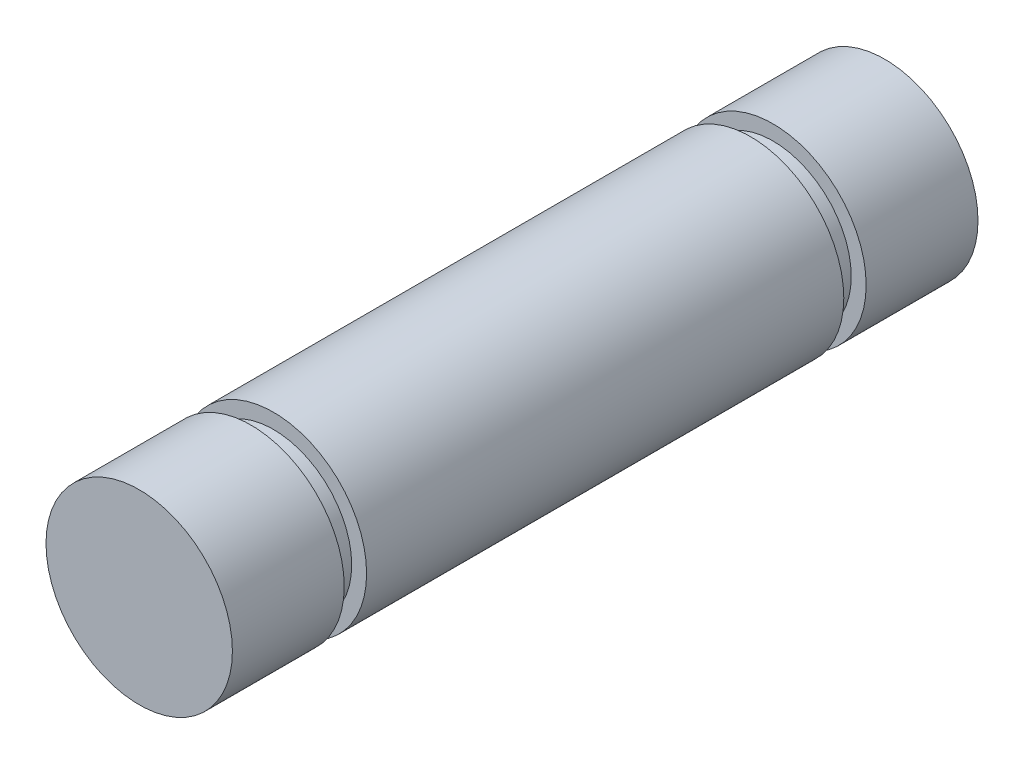
from build123d import *

# Parameters (mm, degrees)
SKETCH1_R           = 3.175
BOSS_EXTRUDE1_DEPTH = 12.7
SKETCH2_W           = 0.508
SKETCH2_H           = 0.762


with BuildPart() as part:
    # Sketch1 → Boss-Extrude1 (new body, symmetric)
    with BuildSketch(Plane.XY):
        Circle(SKETCH1_R)
    extrude(amount=BOSS_EXTRUDE1_DEPTH, both=True)

    # Sketch2 → Cut-Revolve1 (revolve, cut)
    with BuildSketch(Plane(origin=(0, 0, 0), x_dir=(1, 0, 0), z_dir=(0, 1, 0))):
        with Locations((2.921, 8.509)):
            Rectangle(SKETCH2_W, SKETCH2_H)
        with Locations((2.921, -8.509)):
            Rectangle(SKETCH2_W, SKETCH2_H)
    revolve(axis=Axis((0, 0, 12.7), (0, 0, -1)), mode=Mode.SUBTRACT)


solid = part.part
